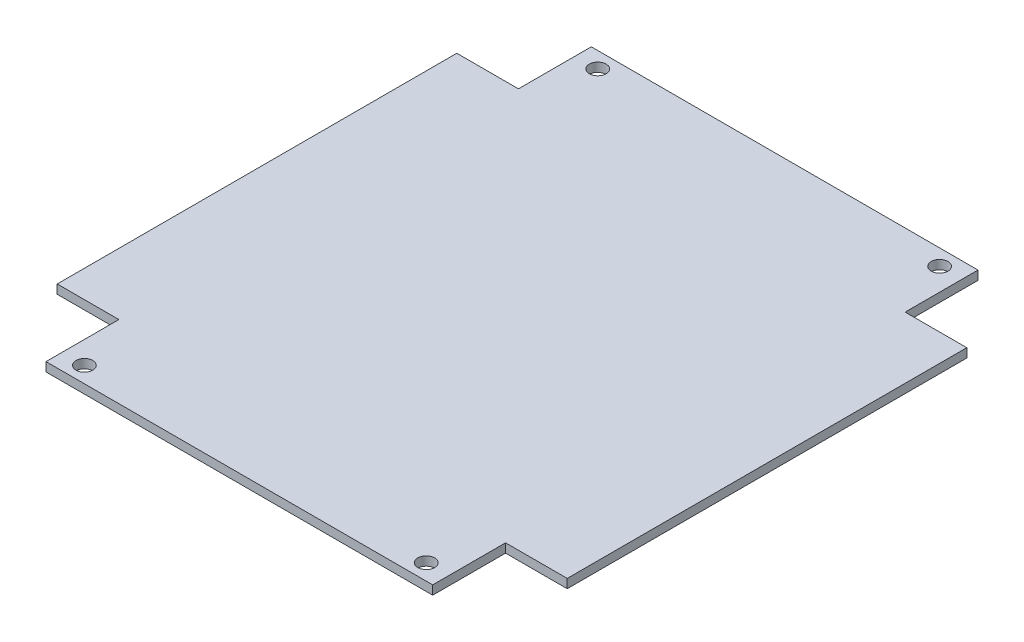
from build123d import *

# Parameters (mm, degrees)
SKETCH1_W           = 91
SKETCH1_H           = 97.3
BOSS_EXTRUDE1_DEPTH = 1.6
SKETCH2_W           = 11
SKETCH2_H           = 13
CUT_EXTRUDE1_DEPTH  = 1.6
SKETCH3_R           = 1.5
CUT_EXTRUDE2_DEPTH  = 1.6


with BuildPart() as part:
    # Sketch1 → Boss-Extrude1 (new body)
    with BuildSketch(Plane(origin=(0, 0, 0), x_dir=(1, 0, 0), z_dir=(0, 1, 0))):
        Rectangle(SKETCH1_W, SKETCH1_H)
    extrude(amount=BOSS_EXTRUDE1_DEPTH)

    # Sketch2 → Cut-Extrude1 (cut)
    with BuildSketch(Plane(origin=(0, 1.6, 0), x_dir=(1, 0, 0), z_dir=(0, 1, 0))):
        with Locations((-40, 42.15)):
            Rectangle(SKETCH2_W, SKETCH2_H)
        with Locations((40, 42.15)):
            Rectangle(SKETCH2_W, SKETCH2_H)
        with Locations((-40, -42.15)):
            Rectangle(SKETCH2_W, SKETCH2_H)
        with Locations((40, -42.15)):
            Rectangle(SKETCH2_W, SKETCH2_H)
    extrude(amount=-CUT_EXTRUDE1_DEPTH, mode=Mode.SUBTRACT)

    # Sketch3 → Cut-Extrude2 (cut)
    with BuildSketch(Plane(origin=(0, 1.6, 0), x_dir=(1, 0, 0), z_dir=(0, 1, 0))):
        with Locations((-30.5, 45.8)):
            Circle(SKETCH3_R)
        with Locations((30.5, 45.8)):
            Circle(SKETCH3_R)
    cut_extrude2 = extrude(amount=-CUT_EXTRUDE2_DEPTH, mode=Mode.SUBTRACT)

    # Mirror1: Cut-Extrude2 across plane
    add(cut_extrude2.mirror(Plane.XY), mode=Mode.SUBTRACT)


solid = part.part
